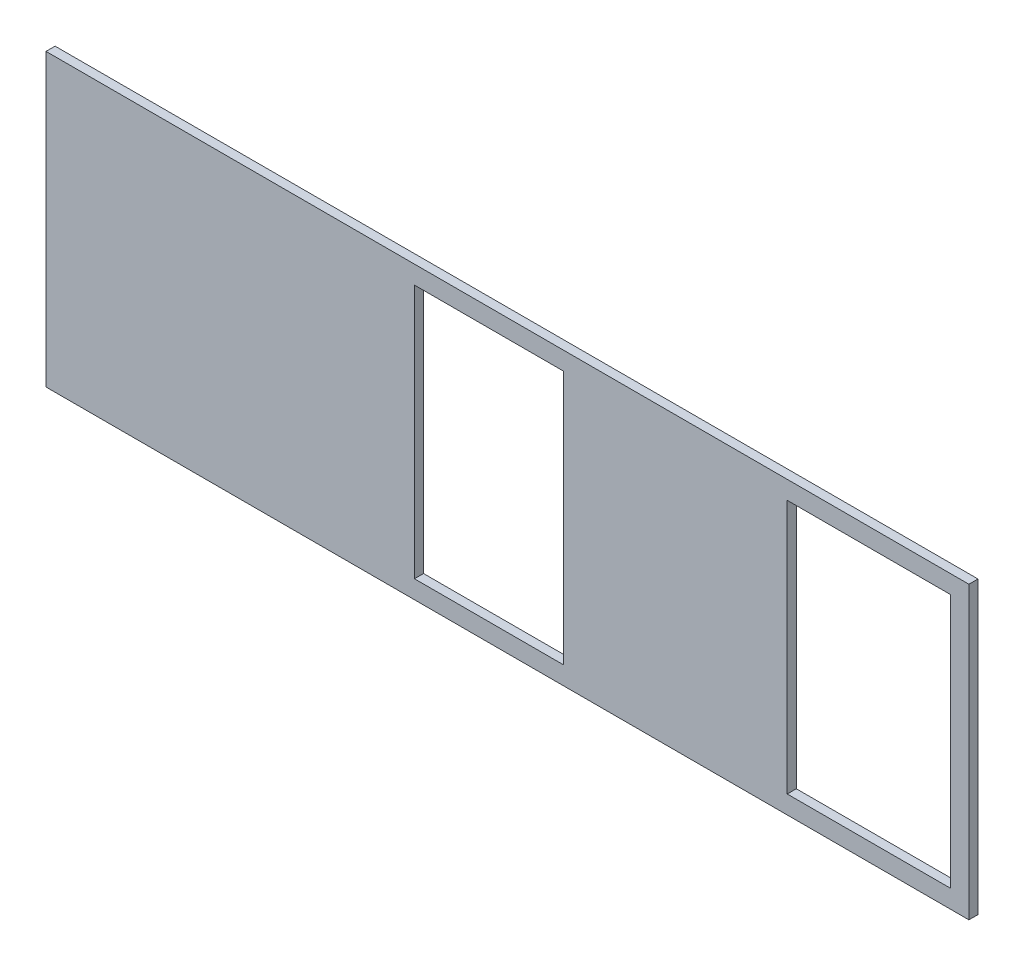
from build123d import *

# Parameters (mm, degrees)
SKETCH1_W           = 322.58
SKETCH1_H           = 101.6
BOSS_EXTRUDE1_DEPTH = 3.175
SKETCH4_W           = 52.07
SKETCH4_H           = 88.9
SKETCH4_W_2         = 57.15
CUT_EXTRUDE1_DEPTH  = 4.175


with BuildPart() as part:
    # Sketch1 → Boss-Extrude1 (new body)
    with BuildSketch(Plane.XY):
        with Locations((161.29, 50.8)):
            Rectangle(SKETCH1_W, SKETCH1_H)
    extrude(amount=BOSS_EXTRUDE1_DEPTH)

    # Sketch4 → Cut-Extrude1 (cut, through all)
    with BuildSketch(Plane.XY.offset(3.175)):
        with Locations((154.813, 50.8)):
            Rectangle(SKETCH4_W, SKETCH4_H)
        with Locations((287.655, 50.8)):
            Rectangle(SKETCH4_W_2, SKETCH4_H)
    extrude(amount=-CUT_EXTRUDE1_DEPTH, mode=Mode.SUBTRACT)


solid = part.part
